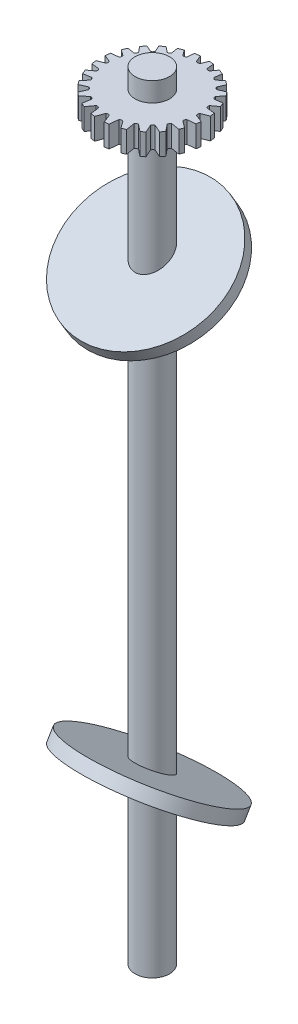
from build123d import *

# Parameters (mm, degrees)
CROQUIS1_R              = 4
SALIENTE_EXTRUIR1_DEPTH = 171
CROQUIS2_R              = 17.5
SALIENTE_EXTRUIR2_DEPTH = 3
SALIENTE_EXTRUIR3_DEPTH = 5
CROQUIS4_R              = 4
SALIENTE_EXTRUIR4_DEPTH = 4.5
CROQUIS8_R              = 17.5
SALIENTE_EXTRUIR6_DEPTH = 3


with BuildPart() as part:
    # Croquis1 → Saliente-Extruir1 (new body)
    with BuildSketch(Plane(origin=(0, 0, 0), x_dir=(1, 0, 0), z_dir=(0, 1, 0))):
        Circle(CROQUIS1_R)
    extrude(amount=SALIENTE_EXTRUIR1_DEPTH)

    # Croquis2 → Saliente-Extruir2 (add)
    with BuildSketch(Plane(origin=(0, 29.389431256, -17.658951857), x_dir=(-1, 0, 0), z_dir=(0, -0.857167301, 0.515038075))):
        with Locations((0, -20.601522996)):
            Circle(CROQUIS2_R)
    extrude(amount=SALIENTE_EXTRUIR2_DEPTH)

    # Croquis3 → Saliente-Extruir3 (add)
    with BuildSketch(Plane(origin=(0, 171, 0), x_dir=(1, 0, 0), z_dir=(0, 1, 0))):
        with BuildLine():
            Line((1.050742858, 12.216507919), (0.472845286, 10.71499343))
            ThreePointArc((0.472845286, 10.71499343), (0, 10.543875222), (-0.472845286, 10.71499343))
            Line((-0.472845286, 10.71499343), (-1.050742858, 12.216507919))
            ThreePointArc((-1.050742858, 12.216507919), (-1.656207782, 12.14924286), (-2.257584572, 12.051988972))
            Line((-2.257584572, 12.051988972), (-2.426564451, 10.457781423))
            ThreePointArc((-2.426564451, 10.457781423), (-2.771930057, 10.239934406), (-3.179948954, 10.255912654))
            Line((-3.179948954, 10.255912654), (-4.120766374, 11.54843759))
            ThreePointArc((-4.120766374, 11.54843759), (-4.690827714, 11.328868507), (-5.249245828, 11.081179745))
            Line((-5.249245828, 11.081179745), (-5.000525386, 9.501805204))
            ThreePointArc((-5.000525386, 9.501805204), (-5.277739988, 9.201993948), (-5.675991453, 9.111824689))
            Line((-5.675991453, 9.111824689), (-6.923284582, 10.120042336))
            ThreePointArc((-6.923284582, 10.120042336), (-7.417219229, 9.763809974), (-7.892857245, 9.383492462))
            Line((-7.892857245, 9.383492462), (-7.239355878, 7.912212973))
            ThreePointArc((-7.239355878, 7.912212973), (-7.429527758, 7.55086912), (-7.790871612, 7.360697239))
            Line((-7.790871612, 7.360697239), (-9.275101788, 8.019950942))
            ThreePointArc((-9.275101788, 8.019950942), (-9.658562641, 7.553760256), (-10.018615343, 7.069262543))
            Line((-10.018615343, 7.069262543), (-8.990483327, 5.797332815))
            ThreePointArc((-8.990483327, 5.797332815), (-9.080652586, 5.39908135), (-9.380463842, 5.121866748))
            Line((-9.380463842, 5.121866748), (-11.018384727, 5.379807088))
            ThreePointArc((-11.018384727, 5.379807088), (-11.266454067, 4.838815873), (-11.487980236, 4.286424664))
            Line((-11.487980236, 4.286424664), (-10.134571292, 3.301290316))
            ThreePointArc((-10.134571292, 3.301290316), (-10.118593045, 2.893271419), (-10.336440061, 2.547905812))
            Line((-10.336440061, 2.547905812), (-12.0307187, 2.368318783))
            ThreePointArc((-12.0307187, 2.368318783), (-12.129855039, 1.792691558), (-12.201465745, 1.212996274))
            Line((-12.201465745, 1.212996274), (-10.593652069, 0.594186647))
            ThreePointArc((-10.593652069, 0.594186647), (-10.472615206, 0.204206132), (-10.593652069, -0.185774383))
            Line((-10.593652069, -0.185774383), (-12.234346993, -0.817239228))
            ThreePointArc((-12.234346993, -0.817239228), (-12.183011813, -1.386127504), (-12.105238209, -1.952007737))
            Line((-12.105238209, -1.952007737), (-10.336440061, -2.139493548))
            ThreePointArc((-10.336440061, -2.139493548), (-10.118593045, -2.484859155), (-10.134571292, -2.892878051))
            Line((-10.134571292, -2.892878051), (-11.603765461, -3.962291436))
            ThreePointArc((-11.603765461, -3.962291436), (-11.411733847, -4.485471759), (-11.196127365, -4.999385795))
            Line((-11.196127365, -4.999385795), (-9.380463842, -4.713454484))
            ThreePointArc((-9.380463842, -4.713454484), (-9.080652586, -4.990669086), (-8.990483327, -5.388920551))
            Line((-8.990483327, -5.388920551), (-10.170571543, -6.848839375))
            ThreePointArc((-10.170571543, -6.848839375), (-9.857154436, -7.29271093), (-9.524379813, -7.722261033))
            Line((-9.524379813, -7.722261033), (-7.790871612, -6.952284975))
            ThreePointArc((-7.790871612, -6.952284975), (-7.429527758, -7.142456856), (-7.239355878, -7.503800709))
            Line((-7.239355878, -7.503800709), (-8.024406446, -9.271247353))
            ThreePointArc((-8.024406446, -9.271247353), (-7.61599094, -9.60956858), (-7.193327687, -9.929912542))
            Line((-7.193327687, -9.929912542), (-5.675991453, -8.703412424))
            ThreePointArc((-5.675991453, -8.703412424), (-5.277739988, -8.793581684), (-5.000525386, -9.09339294))
            Line((-5.000525386, -9.09339294), (-5.309068741, -11.052642915))
            ThreePointArc((-5.309068741, -11.052642915), (-4.836465093, -11.26746341), (-4.355191926, -11.462086615))
            Line((-4.355191926, -11.462086615), (-3.179948954, -9.84750039))
            ThreePointArc((-3.179948954, -9.84750039), (-2.771930057, -9.831522142), (-2.426564451, -10.049369159))
            Line((-2.426564451, -10.049369159), (-2.213426541, -12.060176999))
            ThreePointArc((-2.213426541, -12.060176999), (-1.70946512, -12.141863749), (-1.202540078, -12.202500713))
            Line((-1.202540078, -12.202500713), (-0.472845286, -10.306581166))
            ThreePointArc((-0.472845286, -10.306581166), (-0.08286477, -10.185544303), (0.307115745, -10.306581166))
            Line((0.307115745, -10.306581166), (1.042474215, -12.217216287))
            ThreePointArc((1.042474215, -12.217216287), (1.544818551, -12.163908169), (2.04454079, -12.08995365))
            Line((2.04454079, -12.08995365), (2.26083491, -10.049369159))
            ThreePointArc((2.26083491, -10.049369159), (2.606200516, -9.831522142), (3.014219413, -9.84750039))
            Line((3.014219413, -9.84750039), (4.224886916, -11.510753965))
            ThreePointArc((4.224886916, -11.510753965), (4.693799885, -11.327637394), (5.154801423, -11.125428018))
            Line((5.154801423, -11.125428018), (4.834795845, -9.09339294))
            ThreePointArc((4.834795845, -9.09339294), (5.112010447, -8.793581684), (5.510261912, -8.703412424))
            Line((5.510261912, -8.703412424), (7.105542644, -9.992916993))
            ThreePointArc((7.105542644, -9.992916993), (7.511283882, -9.691632511), (7.90426552, -9.37388462))
            Line((7.90426552, -9.37388462), (7.073626337, -7.503800709))
            ThreePointArc((7.073626337, -7.503800709), (7.263798217, -7.142456856), (7.625142071, -6.952284975))
            Line((7.625142071, -6.952284975), (9.480310931, -7.776299309))
            ThreePointArc((9.480310931, -7.776299309), (9.796043302, -7.374595712), (10.094766478, -6.960087359))
            Line((10.094766478, -6.960087359), (8.824753786, -5.388920551))
            ThreePointArc((8.824753786, -5.388920551), (8.914923046, -4.990669086), (9.214734302, -4.713454484))
            Line((9.214734302, -4.713454484), (11.185209251, -5.023765551))
            ThreePointArc((11.185209251, -5.023765551), (11.388040568, -4.545289685), (11.570414703, -4.058648777))
            Line((11.570414703, -4.058648777), (9.968841751, -2.892878051))
            ThreePointArc((9.968841751, -2.892878051), (9.952863504, -2.484859155), (10.17071052, -2.139493548))
            Line((10.17071052, -2.139493548), (12.108106386, -1.934137026))
            ThreePointArc((12.108106386, -1.934137026), (12.180495026, -1.408072161), (12.230038474, -0.879366378))
            Line((12.230038474, -0.879366378), (10.427922528, -0.185774383))
            ThreePointArc((10.427922528, -0.185774383), (10.306885665, 0.204206132), (10.427922528, 0.594186647))
            Line((10.427922528, 0.594186647), (12.195208041, 1.274373229))
            ThreePointArc((12.195208041, 1.274373229), (12.12666239, 1.8141625), (12.034236318, 2.350379234))
            Line((12.034236318, 2.350379234), (10.17071052, 2.547905812))
            ThreePointArc((10.17071052, 2.547905812), (9.952863504, 2.893271419), (9.968841751, 3.301290316))
            Line((9.968841751, 3.301290316), (11.452232826, 4.381037502))
            ThreePointArc((11.452232826, 4.381037502), (11.241020253, 4.897610638), (11.006520824, 5.404037901))
            Line((11.006520824, 5.404037901), (9.214734302, 5.121866748))
            ThreePointArc((9.214734302, 5.121866748), (8.914923046, 5.39908135), (8.824753786, 5.797332815))
            Line((8.824753786, 5.797332815), (9.940895623, 7.178141856))
            ThreePointArc((9.940895623, 7.178141856), (9.595346713, 7.633901214), (9.228920544, 8.073050965))
            Line((9.228920544, 8.073050965), (7.625142071, 7.360697239))
            ThreePointArc((7.625142071, 7.360697239), (7.263798217, 7.55086912), (7.073626337, 7.912212973))
            Line((7.073626337, 7.912212973), (7.77177818, 9.48401762))
            ThreePointArc((7.77177818, 9.48401762), (7.310768329, 9.843769234), (6.83313078, 10.181132061))
            Line((6.83313078, 10.181132061), (5.510261912, 9.111824689))
            ThreePointArc((5.510261912, 9.111824689), (5.112010447, 9.201993948), (4.834795845, 9.501805204))
            Line((4.834795845, 9.501805204), (5.094829592, 11.15301922))
            ThreePointArc((5.094829592, 11.15301922), (4.547139411, 11.387302116), (3.988716959, 11.594708419))
            Line((3.988716959, 11.594708419), (3.014219413, 10.255912654))
            ThreePointArc((3.014219413, 10.255912654), (2.606200516, 10.239934406), (2.26083491, 10.457781423))
            Line((2.26083491, 10.457781423), (2.088629995, 12.082414951))
            ThreePointArc((2.088629995, 12.082414951), (1.571117662, 12.16053928), (1.050742858, 12.216507919))
        make_face()
    extrude(amount=SALIENTE_EXTRUIR3_DEPTH)

    # Croquis4 → Saliente-Extruir4 (add)
    with BuildSketch(Plane(origin=(0, 176, 0), x_dir=(1, 0, 0), z_dir=(0, 1, 0))):
        Circle(CROQUIS4_R)
    extrude(amount=SALIENTE_EXTRUIR4_DEPTH)

    # Croquis8 → Saliente-Extruir6 (add)
    with BuildSketch(Plane(origin=(0, 102.863009395, 61.8063315), x_dir=(-1, 0, 0), z_dir=(0, 0.857167301, 0.515038075))):
        with Locations((0, -72.105330487)):
            Circle(CROQUIS8_R)
    extrude(amount=SALIENTE_EXTRUIR6_DEPTH)


solid = part.part
